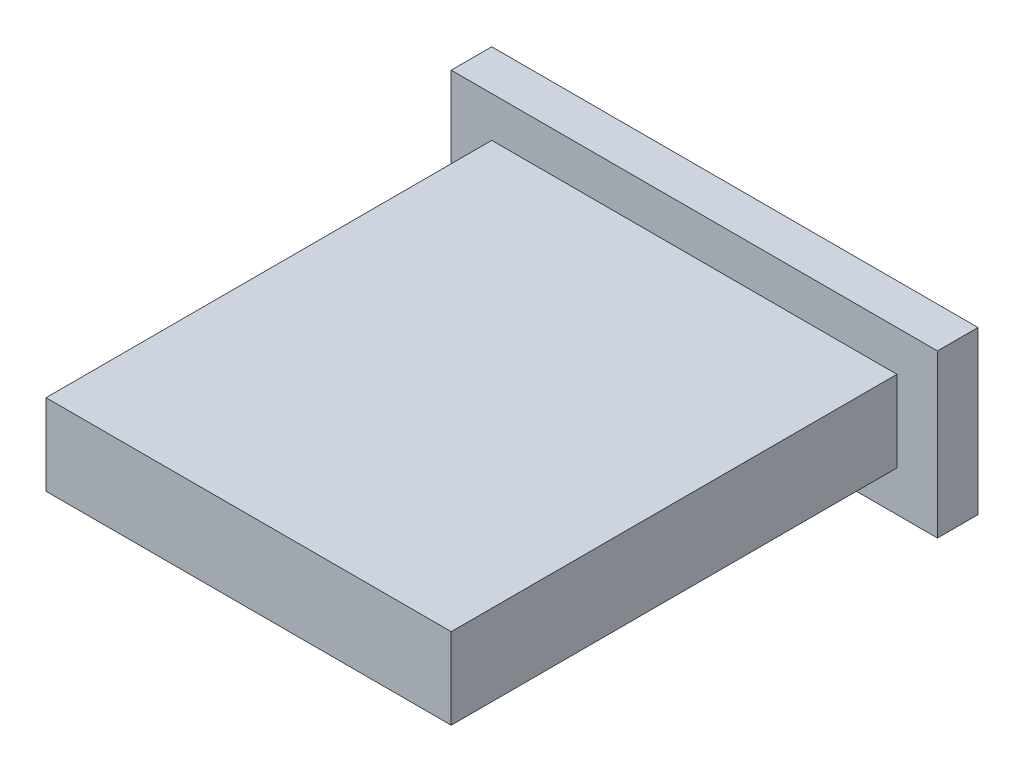
from build123d import *

# Parameters (mm, degrees)
SCHIZZO1_W                   = 10
SCHIZZO1_H                   = 2
ESTRUSIONE_ESTRUSIONE1_DEPTH = 11
SCHIZZO1_4_W                 = 12
SCHIZZO1_4_H                 = 4
SCHIZZO1_4_W_2               = 10
SCHIZZO1_4_H_2               = 2
ESTRUSIONE_ESTRUSIONE2_DEPTH = 1


with BuildPart() as part:
    # Schizzo1 → Estrusione-Estrusione1 (new body)
    with BuildSketch(Plane.XY):
        Rectangle(SCHIZZO1_W, SCHIZZO1_H)
    extrude(amount=ESTRUSIONE_ESTRUSIONE1_DEPTH)


with BuildPart() as body_2:
    # Schizzo1_4 → Estrusione-Estrusione2 (new body)
    with BuildSketch(Plane.XY):
        Rectangle(SCHIZZO1_4_W, SCHIZZO1_4_H)
        Rectangle(SCHIZZO1_4_W_2, SCHIZZO1_4_H_2, mode=Mode.SUBTRACT)
    extrude(amount=-ESTRUSIONE_ESTRUSIONE2_DEPTH)


solid = Compound([part.part, body_2.part])
